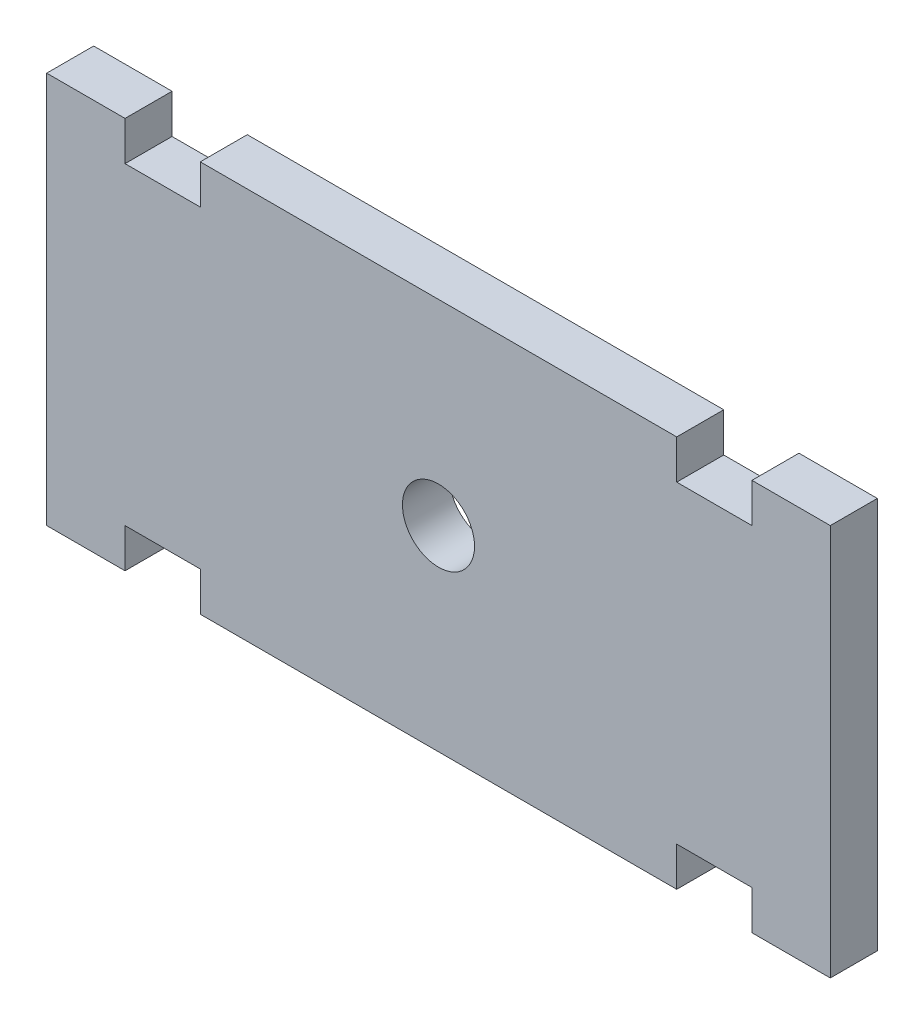
from build123d import *

# Parameters (mm, degrees)
BOSS_EXTRUDE1_DEPTH = 3
SKETCH2_R           = 2.3
CUT_EXTRUDE1_DEPTH  = 3


with BuildPart() as part:
    # Sketch1 → Boss-Extrude1 (new body)
    with BuildSketch(Plane.XY):
        Polygon((-20, 12.5), (-20, 10), (-15.2, 10), (-15.2, 12.5), (15.2, 12.5), (15.2, 10), (20, 10), (20, 12.5), (25, 12.5), (25, -12.5), (20, -12.5), (20, -10), (15.2, -10), (15.2, -12.5), (-15.2, -12.5), (-15.2, -10), (-20, -10), (-20, -12.5), (-25, -12.5), (-25, 12.5), align=None)
    extrude(amount=-BOSS_EXTRUDE1_DEPTH)

    # Sketch2 → Cut-Extrude1 (cut)
    with BuildSketch(Plane.XY):
        Circle(SKETCH2_R)
    extrude(amount=-CUT_EXTRUDE1_DEPTH, mode=Mode.SUBTRACT)


solid = part.part
